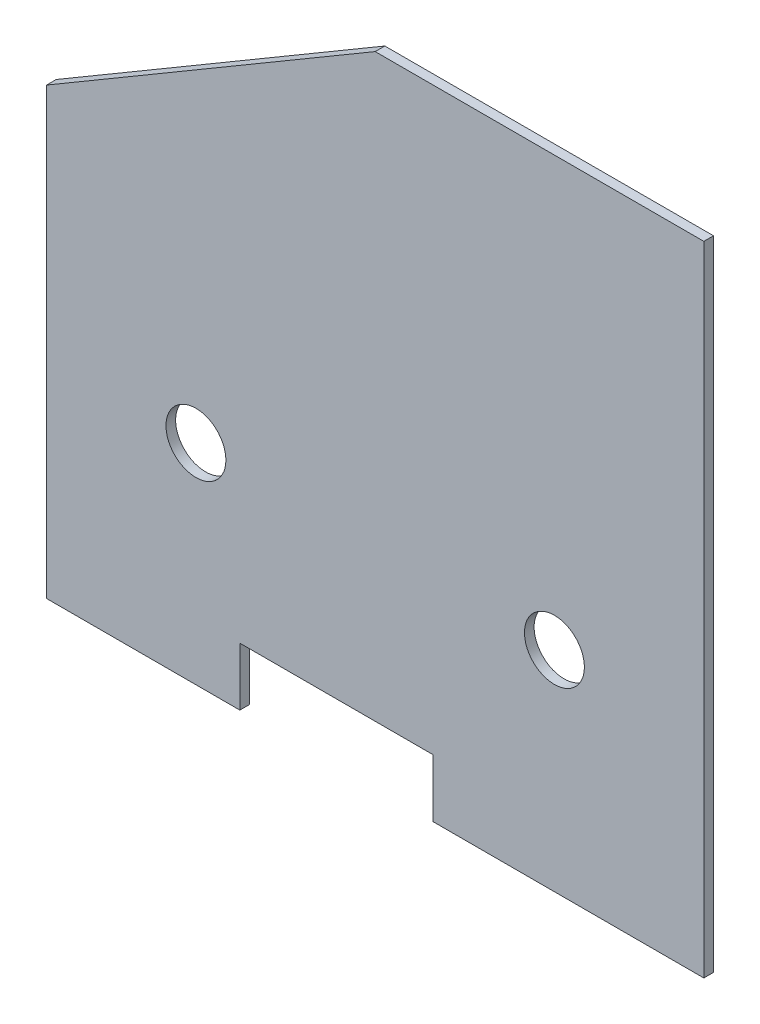
from build123d import *

# Parameters (mm, degrees)
BOSS_EXTRUDE1_DEPTH = 6.35
SKETCH3_R           = 19.685
CUT_EXTRUDE1_DEPTH  = 7.35


with BuildPart() as part:
    # Sketch2 → Boss-Extrude1 (new body)
    with BuildSketch(Plane.XY):
        Polygon((0, 304.8), (0, 12.7), (127, 12.7), (127, 50.8), (254, 50.8), (254, 12.7), (431.8, 12.7), (431.8, 431.8), (215.9, 431.8), align=None)
    extrude(amount=BOSS_EXTRUDE1_DEPTH)

    # Sketch3 → Cut-Extrude1 (cut, through all)
    with BuildSketch(Plane.XY.offset(6.35)):
        with Locations((98.15, 150.3)):
            Circle(SKETCH3_R)
        with Locations((333.65, 150.3)):
            Circle(SKETCH3_R)
    extrude(amount=-CUT_EXTRUDE1_DEPTH, mode=Mode.SUBTRACT)


solid = part.part
